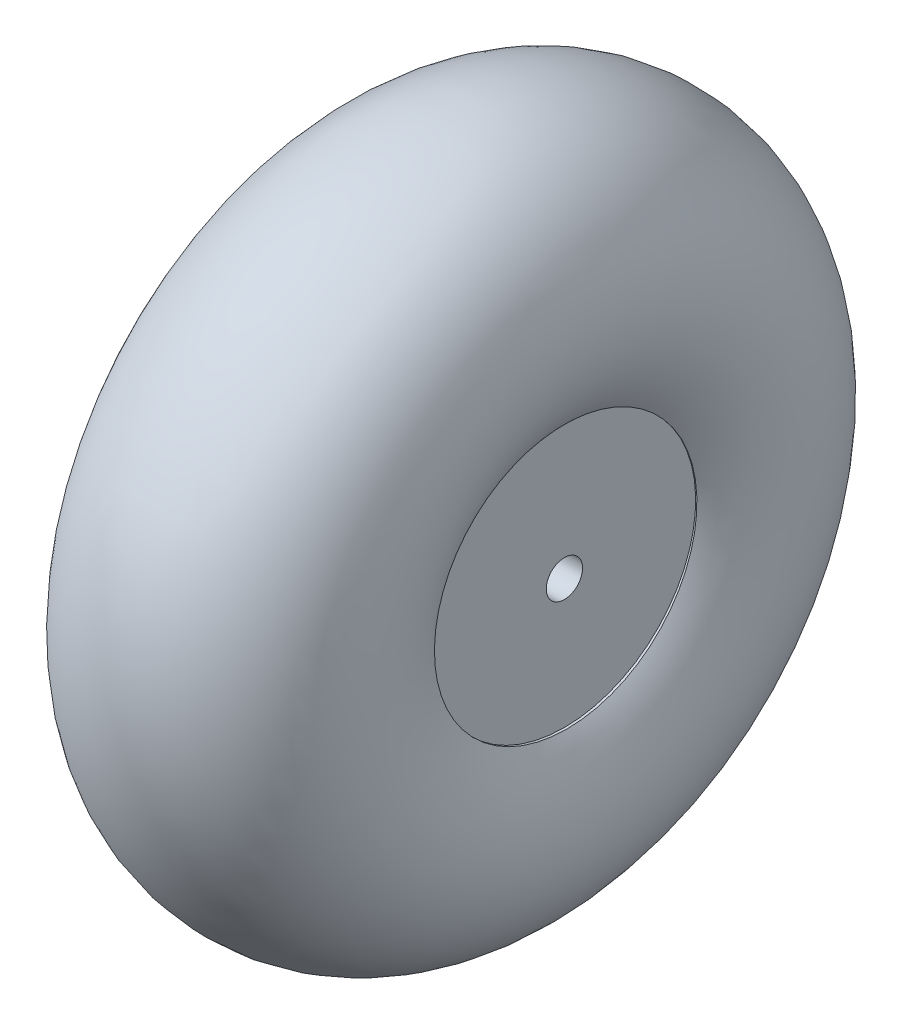
from build123d import *

# Parameters (mm, degrees)
SKETCH1_W = 12.7
SKETCH1_H = 6.35


with BuildPart() as part:
    # Sketch1 → Revolve1 (revolve)
    with BuildSketch(Plane.XY):
        with Locations((6.35, 4.175)):
            Rectangle(SKETCH1_W, SKETCH1_H)
    revolve(axis=Axis((0, 0, 0), (1, 0, 0)))


with BuildPart() as body_2:
    # Sketch2 → Revolve8 (revolve)
    with BuildSketch(Plane.XY):
        with BuildLine():
            Line((0, 7.35), (12.7, 7.35))
            ThreePointArc((12.7, 7.35), (6.35, 19.182113484), (0, 7.35))
        make_face()
    revolve(axis=Axis((0, 0, 0), (0.999952636, 0.009732767, 0)))


solid = Compound([part.part, body_2.part])
